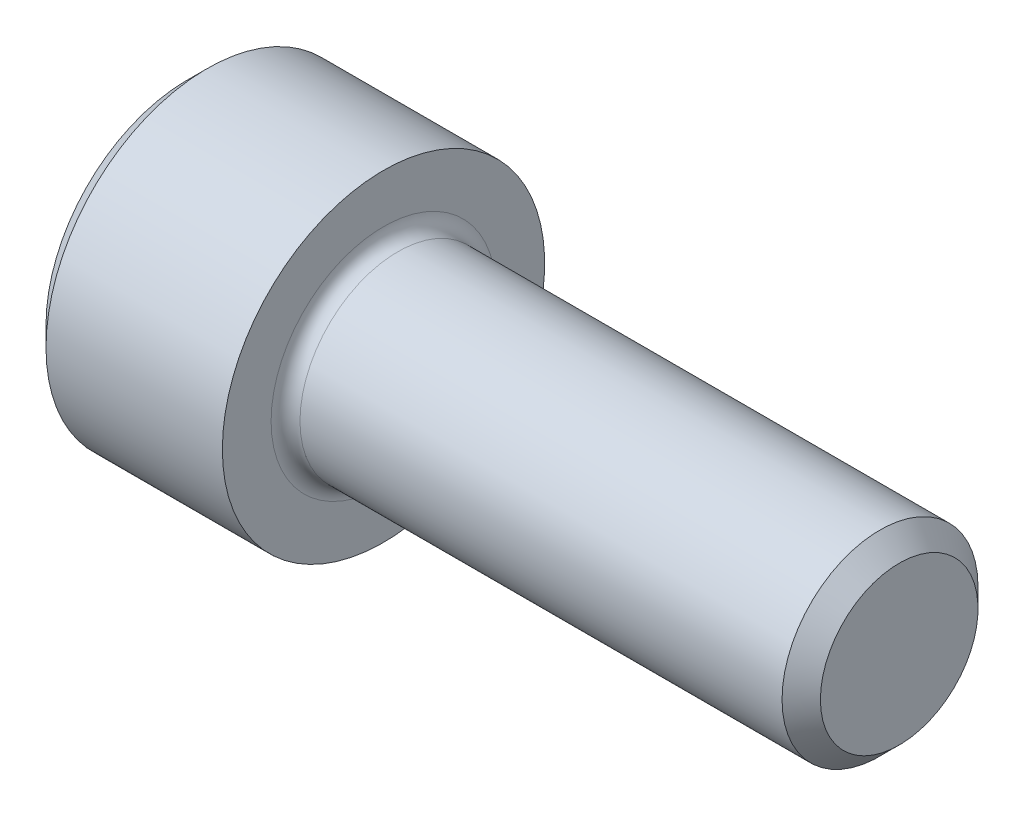
from build123d import *

# Parameters (mm, degrees)
FILLET1_R   = 0.3556
HEX_2_DEPTH = 2.286


with BuildPart() as part:
    # BodySke → Base-Revolve (revolve)
    with BuildSketch(Plane.XY):
        Polygon((0, 0), (0, 3.48615), (0.4826, 3.96875), (4.826, 3.96875), (4.826, 2.413), (17.05356, 2.413), (17.526, 1.94056), (17.526, 0), align=None)
    revolve(axis=Axis((-31.75, 0, 0), (1, 0, 0)))

    # Fillet1
    fillet1_edges = [part.edges().sort_by_distance(p)[0] for p in [
        (4.826, -2.413, 0),
    ]]
    fillet(fillet1_edges, radius=FILLET1_R)

    # Sketch2 → Hex-PreBroach (revolve, cut)
    with BuildSketch(Plane.XY):
        Polygon((0, 1.98501), (2.286, 1.98501), (3.432046058, 0), (0, 0), align=None)
    revolve(axis=Axis((0, 0, 0), (1, 0, 0)), mode=Mode.SUBTRACT)

    # Sketch3 → Hex 2 (cut)
    with BuildSketch(Plane(origin=(0, 0, 0), x_dir=(0, 0.5, 0.866025404), z_dir=(-1, 0, 0))):
        Polygon((1.146046058, 1.98501), (-1.146046058, 1.98501), (-2.292092116, 0), (-1.146046058, -1.98501), (1.146046058, -1.98501), (2.292092116, 0), align=None)
    extrude(amount=-HEX_2_DEPTH, mode=Mode.SUBTRACT)


solid = part.part
